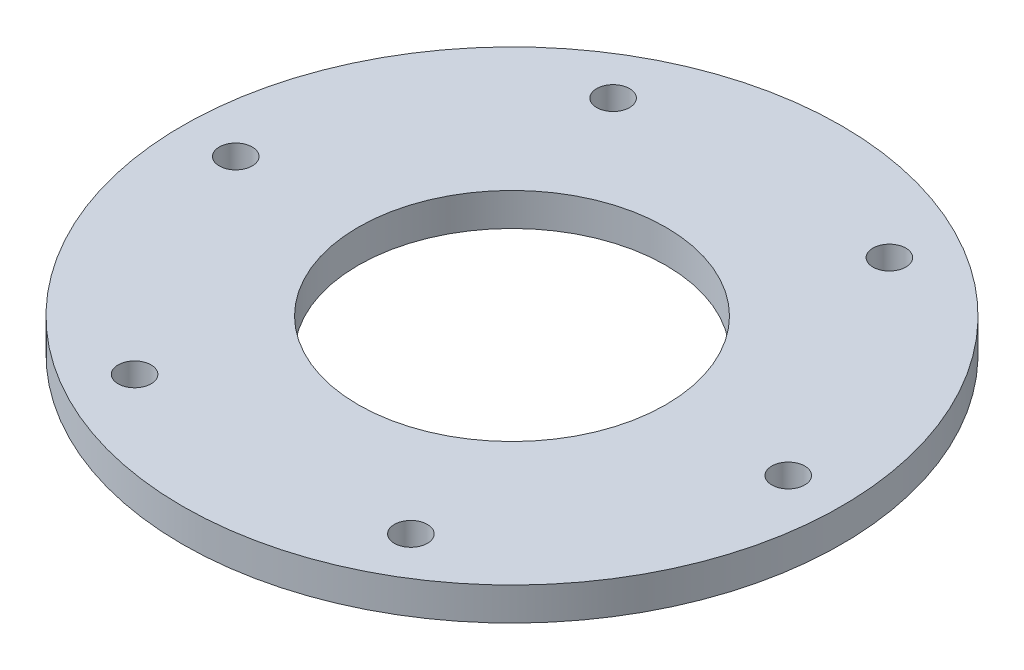
from build123d import *

# Parameters (mm, degrees)
SKETCH1_R           = 30
SKETCH1_R_2         = 1.5
SKETCH1_R_3         = 14
BOSS_EXTRUDE1_DEPTH = 3


with BuildPart() as part:
    # Sketch1 → Boss-Extrude1 (new body)
    with BuildSketch(Plane(origin=(0, 0, 0), x_dir=(1, 0, 0), z_dir=(0, 1, 0))):
        Circle(SKETCH1_R)
        with Locations((-25.15, 0)):
            Circle(SKETCH1_R_2, mode=Mode.SUBTRACT)
        Circle(SKETCH1_R_3, mode=Mode.SUBTRACT)
        with Locations((-12.575, 21.780538905)):
            Circle(SKETCH1_R_2, mode=Mode.SUBTRACT)
        with Locations((12.575, 21.780538905)):
            Circle(SKETCH1_R_2, mode=Mode.SUBTRACT)
        with Locations((25.15, 0)):
            Circle(SKETCH1_R_2, mode=Mode.SUBTRACT)
        with Locations((12.575, -21.780538905)):
            Circle(SKETCH1_R_2, mode=Mode.SUBTRACT)
        with Locations((-12.575, -21.780538905)):
            Circle(SKETCH1_R_2, mode=Mode.SUBTRACT)
    extrude(amount=BOSS_EXTRUDE1_DEPTH)


solid = part.part
